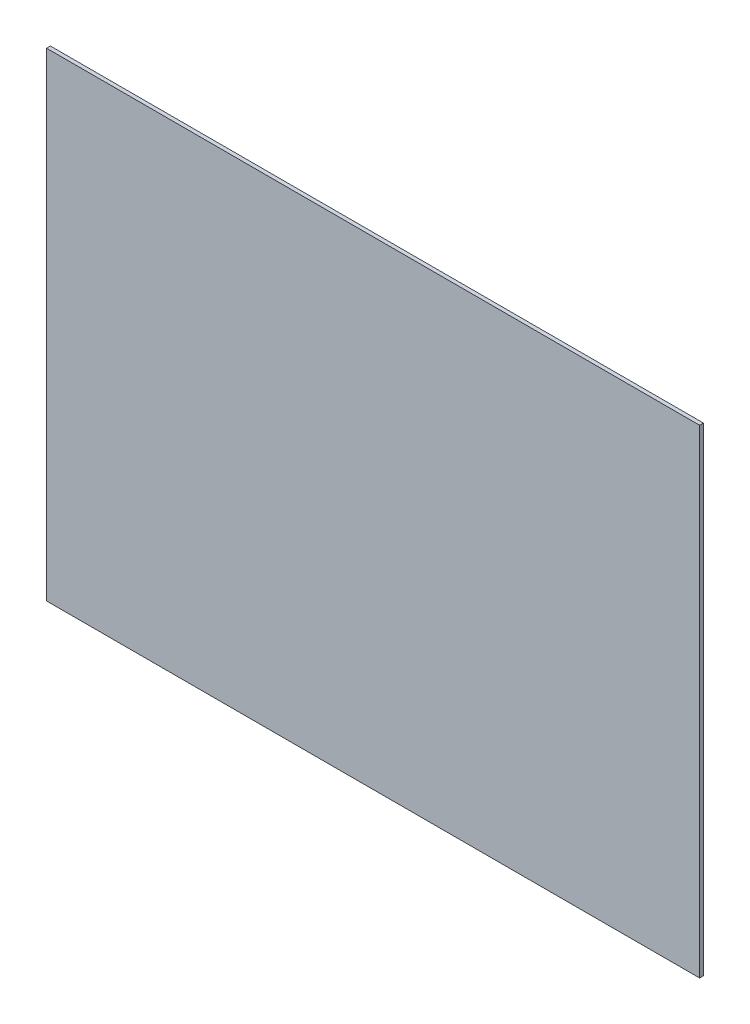
from build123d import *

# Parameters (mm, degrees)
SKETCH1_W           = 273.05
SKETCH1_H           = 200.152
BOSS_EXTRUDE1_DEPTH = 1.6002


with BuildPart() as part:
    # Sketch1 → Boss-Extrude1 (new body)
    with BuildSketch(Plane.XY):
        Rectangle(SKETCH1_W, SKETCH1_H)
    extrude(amount=BOSS_EXTRUDE1_DEPTH)


solid = part.part
